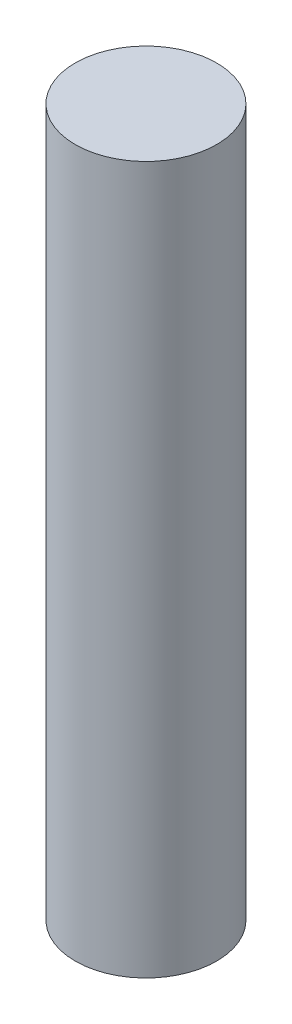
from build123d import *

# Parameters (mm, degrees)
SKETCH1_R           = 2
BOSS_EXTRUDE1_DEPTH = 20


with BuildPart() as part:
    # Sketch1 → Boss-Extrude1 (new body)
    with BuildSketch(Plane(origin=(0, 0, 0), x_dir=(1, 0, 0), z_dir=(0, 1, 0))):
        Circle(SKETCH1_R)
    extrude(amount=BOSS_EXTRUDE1_DEPTH)


solid = part.part
